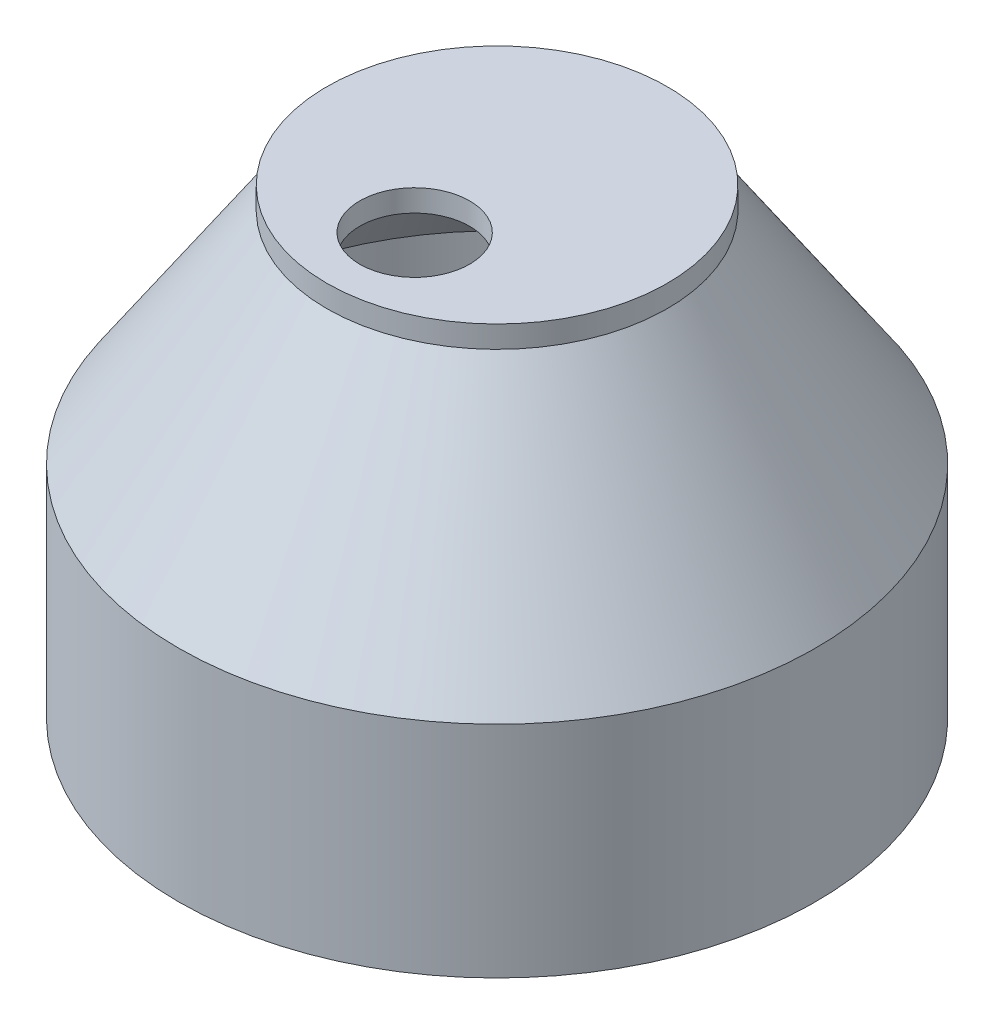
from build123d import *

# Parameters (mm, degrees)
IZIM6_R                     = 15.5
IZIM6_R_2                   = 5
Y_KSEKLIK_EKSTR_ZYON2_DEPTH = 2


with BuildPart() as part:
    # Çizim5 → Döndür1 (revolve)
    with BuildSketch(Plane(origin=(0, 0, 0), x_dir=(0, 0, -1), z_dir=(1, 0, 0))):
        Polygon((12.5, 20), (15.5, 20), (29, 0), (29, -20), (26, -20), (26, 0), align=None)
    revolve(axis=Axis((0, 40.284256648, 0), (0, -1, 0)))

    # Çizim6 → Yükseklik-Ekstrüzyon2 (add)
    with BuildSketch(Plane(origin=(0, 20, 0), x_dir=(1, 0, 0), z_dir=(0, 1, 0))):
        Circle(IZIM6_R)
        with Locations((0, -7.5)):
            Circle(IZIM6_R_2, mode=Mode.SUBTRACT)
    extrude(amount=Y_KSEKLIK_EKSTR_ZYON2_DEPTH)


solid = part.part
